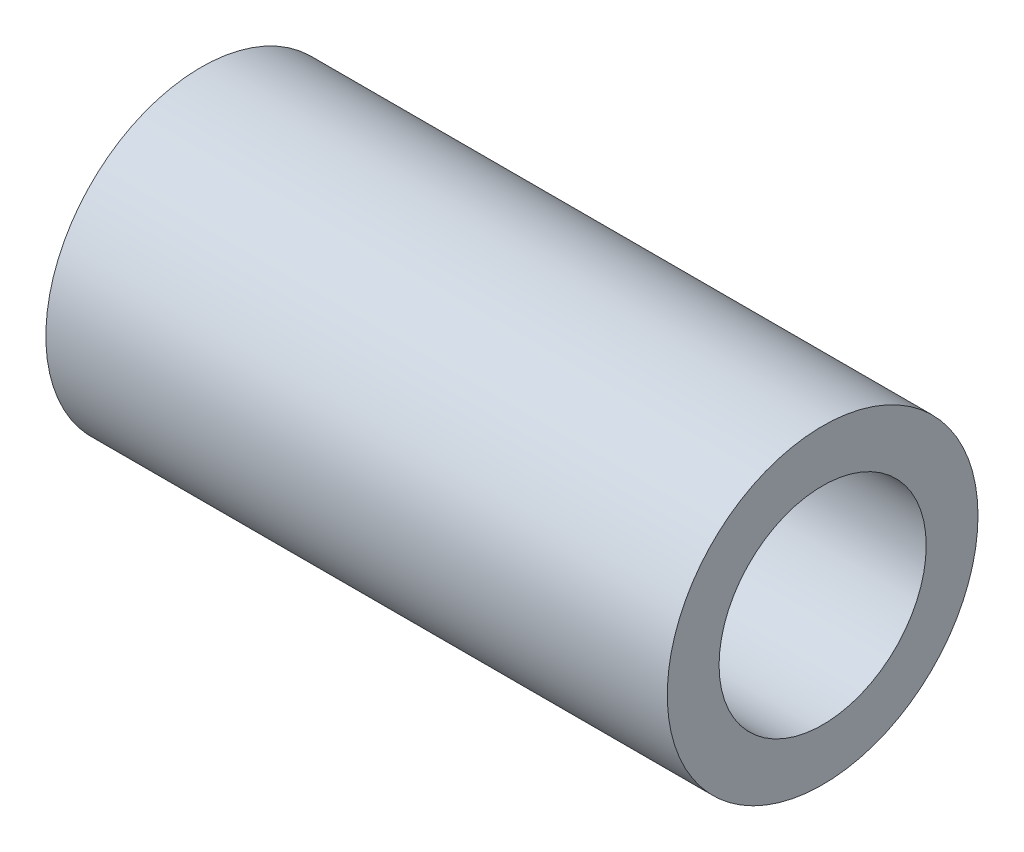
from build123d import *

# Parameters (mm, degrees)
SKETCH1_R           = 4.7625
SKETCH1_R_2         = 3.175
EXTRUDE1_DEPTH      = 9.525
EXTRUDE1_DEPTH_BACK = 9.525


with BuildPart() as part:
    # Sketch1 → Extrude1 (new body, two sides)
    with BuildSketch(Plane(origin=(0, 0, 0), x_dir=(0, 0, -1), z_dir=(1, 0, 0))) as extrude1_sk:
        Circle(SKETCH1_R)
        Circle(SKETCH1_R_2, mode=Mode.SUBTRACT)
    extrude(amount=EXTRUDE1_DEPTH)
    extrude(extrude1_sk.sketch, amount=-EXTRUDE1_DEPTH_BACK)


solid = part.part
